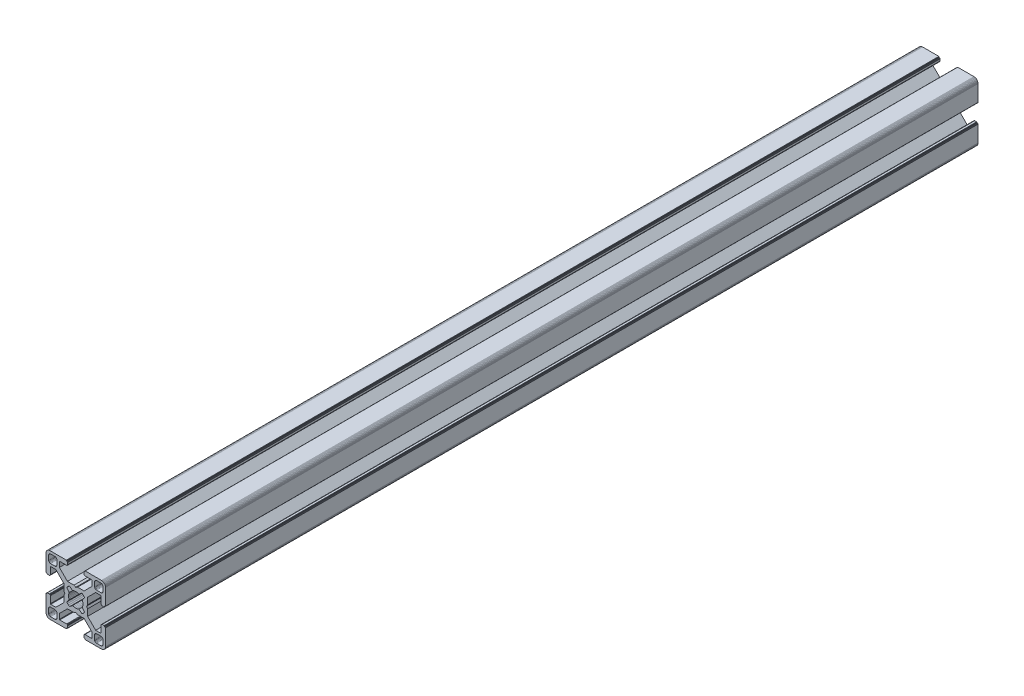
from build123d import *

# Parameters (mm, degrees)
BOSS_EXTRUDE1_DEPTH = 440


with BuildPart() as part:
    # Sketch1 → Boss-Extrude1 (new body)
    with BuildSketch(Plane.XY):
        Polygon((28.34729664, 29.969613999), (28.000000864, 29.999999329), (19.750000909, 29.999999329), (19.715268165, 29.996961355), (19.681595266, 29.987938702), (19.649999216, 29.973205179), (19.621443003, 29.953207821), (19.596790895, 29.928557575), (19.576793537, 29.899999499), (19.562061876, 29.868405312), (19.55303736, 29.834728688), (19.549999386, 29.799999669), (19.549999386, 29.699999839), (19.546961412, 29.665268958), (19.537936896, 29.631596059), (19.523203373, 29.599998146), (19.503207877, 29.571441934), (19.478557631, 29.546789825), (19.449999556, 29.526794329), (19.418403506, 29.512060806), (19.384728745, 29.503038153), (19.349999726, 29.500000179), (19.249999896, 29.500000179), (19.215267517, 29.496958527), (19.181592755, 29.487935874), (19.149996706, 29.47320235), (19.12143863, 29.453206855), (19.096788384, 29.428554746), (19.076791026, 29.399996671), (19.062057503, 29.368402484), (19.05303485, 29.334725859), (19.049996876, 29.299998703), (19.049996876, 28.39999837), (19.059110798, 28.29580945), (19.08618062, 28.194785165), (19.13038119, 28.099997016), (19.190369539, 28.014324653), (19.264324002, 27.94037019), (19.349996366, 27.88038184), (19.444784515, 27.836181271), (19.545806937, 27.809111449), (19.650010894, 27.799984574), (23.050010706, 27.799984574), (23.084741588, 27.7969466), (23.118414487, 27.787923946), (23.150012399, 27.773190423), (23.178568612, 27.753193065), (23.203220721, 27.728542819), (23.223218079, 27.699984744), (23.237949739, 27.668386831), (23.246974255, 27.634713932), (23.25001142, 27.59998608), (23.25001142, 25.049987618), (19.204474482, 20.999982084), (15.900007876, 20.999982084), (15.000008474, 20.48483404), (14.10000814, 20.999982084), (10.795543398, 20.999982084), (7.997342887, 23.801274731), (6.750011387, 25.049984589), (6.750011387, 27.599983051), (6.753049362, 27.634713932), (6.762072946, 27.668386831), (6.776805538, 27.699984744), (6.796801965, 27.728542819), (6.821454073, 27.753193065), (6.850011218, 27.773190423), (6.881607267, 27.787923946), (6.915282029, 27.7969466), (6.950011048, 27.799984574), (10.350011791, 27.799984574), (10.45420071, 27.809098497), (10.555223133, 27.836168318), (10.650011282, 27.880368888), (10.735683645, 27.940357238), (10.809638108, 28.014311701), (10.869626458, 28.099984064), (10.913827027, 28.194772213), (10.940895918, 28.295796498), (10.950010772, 28.399985417), (10.950010772, 29.299985751), (10.946974575, 29.334739239), (10.93795065, 29.368415522), (10.923215933, 29.400009153), (10.903218427, 29.428566473), (10.878566319, 29.45321765), (10.849999264, 29.473204166), (10.818403214, 29.487937689), (10.784728453, 29.496960342), (10.749999434, 29.500000179), (10.649999604, 29.500000179), (10.615270585, 29.503038153), (10.581595823, 29.512060806), (10.549999774, 29.526794329), (10.521441698, 29.546789825), (10.496791452, 29.571441934), (10.476795025, 29.599998146), (10.462061502, 29.631596059), (10.453037918, 29.665268958), (10.449999943, 29.699999839), (10.449999943, 29.799999669), (10.446961969, 29.834728688), (10.437938385, 29.868405312), (10.423205793, 29.899999499), (10.403208435, 29.928557575), (10.378557257, 29.953207821), (10.350000113, 29.973205179), (10.318404064, 29.987938702), (10.284729302, 29.996961355), (10.250000283, 29.999999329), (1.999999397, 29.999999329), (1.652702689, 29.969613999), (1.315958682, 29.879383743), (0.999999233, 29.732050374), (0.714424066, 29.532089829), (0.467910431, 29.285576195), (0.267948955, 28.999999166), (0.120614655, 28.684040532), (0.030384399, 28.34729664), (0, 28.000000864), (0, 19.750000909), (0.003037974, 19.715268165), (0.012061559, 19.681595266), (0.026795082, 19.649999216), (0.046790577, 19.621441141), (0.071442686, 19.596789032), (0.09999983, 19.576793537), (0.13159588, 19.562060013), (0.165270641, 19.55303736), (0.19999966, 19.549999386), (0.299999461, 19.549999386), (0.334728509, 19.546959549), (0.368403242, 19.537936896), (0.399999321, 19.523203373), (0.428556465, 19.503207877), (0.453208573, 19.478555769), (0.473204069, 19.449997693), (0.487937592, 19.418403506), (0.496961176, 19.384728745), (0.499999151, 19.349999726), (0.499999151, 19.249998033), (0.503038056, 19.215269014), (0.512060709, 19.181594253), (0.526794232, 19.150000066), (0.546790194, 19.121441524), (0.571441837, 19.096789882), (0.60000029, 19.076794925), (0.631595686, 19.062061999), (0.665270619, 19.053039982), (0.700000626, 19.050000801), (1.60000096, 19.050000801), (1.704189879, 19.059116587), (1.805213233, 19.086186409), (1.90000045, 19.130385115), (1.985673745, 19.190375328), (2.059627277, 19.264327928), (2.119616325, 19.350002154), (2.163816196, 19.444788441), (2.190886018, 19.545812726), (2.200000872, 19.650001645), (2.200000872, 23.050001457), (2.203039777, 23.084732338), (2.212062431, 23.118405237), (2.226795954, 23.15000315), (2.246792381, 23.178559362), (2.271443558, 23.203211471), (2.300000702, 23.223206967), (2.331596752, 23.23794049), (2.365271513, 23.246965006), (2.400001464, 23.250001117), (4.950000857, 23.250001117), (7.997332093, 20.202670812), (8.995535423, 19.204467788), (8.995535423, 15.900001182), (9.515148227, 15.00000178), (8.995535423, 14.100002378), (8.995535423, 10.795536704), (4.950000857, 6.750002138), (2.400001464, 6.750002138), (2.365271513, 6.753040112), (2.331596752, 6.762063697), (2.300000702, 6.77679722), (2.271443558, 6.796793647), (2.246792381, 6.821444824), (2.226795954, 6.850001968), (2.212062431, 6.881598018), (2.203039777, 6.915272779), (2.200000872, 6.950002729), (2.200000872, 10.350002542), (2.190896812, 10.454174265), (2.16382699, 10.555197618), (2.119627119, 10.649984836), (2.059638071, 10.735658131), (1.985684539, 10.809611663), (1.900011244, 10.869600944), (1.805224027, 10.913800582), (1.704200673, 10.940870404), (1.600011754, 10.949986189), (0.70001142, 10.949986189), (0.665281355, 10.946948596), (0.631606253, 10.937926283), (0.600010578, 10.923193954), (0.571451747, 10.903199537), (0.546799638, 10.87854836), (0.526794232, 10.850000195), (0.512060709, 10.818404146), (0.503038056, 10.784730315), (0.499999151, 10.750000365), (0.499999151, 10.650000535), (0.496961176, 10.615270585), (0.487937592, 10.581596754), (0.473204069, 10.550000705), (0.453208573, 10.521443561), (0.428556465, 10.496791452), (0.399999321, 10.476795956), (0.368403242, 10.462062433), (0.334728509, 10.453038849), (0.299999461, 10.449999943), (0.19999966, 10.449999943), (0.165270641, 10.446961969), (0.13159588, 10.437939316), (0.09999983, 10.423205793), (0.071442686, 10.403209366), (0.046790577, 10.378558189), (0.026795082, 10.350000113), (0.012061559, 10.318404064), (0.003037974, 10.284729302), (0, 10.250000283), (0, 1.999999397), (0.030384399, 1.652702689), (0.120614655, 1.315958682), (0.267948955, 0.999999233), (0.467910431, 0.714424066), (0.714424066, 0.467910431), (0.999999233, 0.267948955), (1.315958682, 0.120614655), (1.652702689, 0.030384399), (1.999999397, 0), (10.250000283, 0), (10.284729302, 0.003037974), (10.318404064, 0.012061559), (10.350000113, 0.026795082), (10.378557257, 0.046790577), (10.403208435, 0.071442686), (10.423205793, 0.09999983), (10.437938385, 0.13159588), (10.446961969, 0.165270641), (10.449999943, 0.19999966), (10.449999943, 0.300000422), (10.453037918, 0.334729441), (10.462061502, 0.368404202), (10.476795025, 0.400000252), (10.496791452, 0.428557396), (10.521441698, 0.453208573), (10.549999774, 0.473205), (10.581595823, 0.487938523), (10.615270585, 0.496961176), (10.649999604, 0.500000082), (10.749999434, 0.500000082), (10.784728453, 0.503038056), (10.818403214, 0.512060709), (10.849999264, 0.526794232), (10.878547894, 0.546800104), (10.903198606, 0.571451747), (10.923194493, 0.6000102), (10.93792742, 0.631606528), (10.946949437, 0.66528146), (10.950010772, 0.699984975), (10.950010772, 1.599985308), (10.940895918, 1.704174228), (10.913827027, 1.805197581), (10.869626458, 1.89998573), (10.809638108, 1.985658094), (10.735683645, 2.059612557), (10.650011282, 2.119600674), (10.555223133, 2.163801476), (10.45420071, 2.190870367), (10.350011791, 2.199985221), (6.950011048, 2.199985221), (6.915282029, 2.203024126), (6.881607267, 2.212046779), (6.850011218, 2.226780302), (6.821454073, 2.246776729), (6.796801965, 2.271427907), (6.776805538, 2.299985982), (6.762072946, 2.331582032), (6.753049362, 2.365256793), (6.750011387, 2.399985812), (6.750011387, 4.949985206), (9.787457566, 7.990785077), (10.795545277, 8.999985833), (14.100010019, 8.999985833), (15.000010353, 9.515133877), (15.900009756, 8.999985833), (19.204476361, 8.999985833), (20.21256413, 7.990786065), (23.25001142, 4.949988235), (23.25001142, 2.399988841), (23.246974255, 2.365256793), (23.237949739, 2.331582032), (23.223218079, 2.299985982), (23.203220721, 2.271427907), (23.178568612, 2.246776729), (23.150012399, 2.226780302), (23.118414487, 2.212046779), (23.084741588, 2.203024126), (23.050010706, 2.199985221), (19.650010894, 2.199985221), (19.545806937, 2.190883319), (19.444784515, 2.163814428), (19.349996366, 2.119613626), (19.264324002, 2.059625509), (19.190369539, 1.985671046), (19.13038119, 1.899998682), (19.08618062, 1.805210533), (19.059110798, 1.70418718), (19.049996876, 1.599998261), (19.049996876, 0.699997927), (19.053035506, 0.665268966), (19.062058795, 0.631594374), (19.076792915, 0.599998603), (19.096790813, 0.571440905), (19.121441524, 0.546790194), (19.149999978, 0.526794306), (19.181596306, 0.51206138), (19.215271238, 0.503039363), (19.249999896, 0.500000082), (19.349999726, 0.500000082), (19.384728745, 0.496961176), (19.418403506, 0.487938523), (19.449999556, 0.473205), (19.478557631, 0.453208573), (19.503207877, 0.428557396), (19.523203373, 0.400000252), (19.537936896, 0.368404202), (19.546961412, 0.334729441), (19.549999386, 0.300000422), (19.549999386, 0.19999966), (19.55303736, 0.165270641), (19.562061876, 0.13159588), (19.576793537, 0.09999983), (19.596789964, 0.071441755), (19.621442072, 0.046789646), (19.649998285, 0.02679415), (19.681594335, 0.012060627), (19.715267234, 0.003037043), (19.750000909, 0), (28.000000864, 0), (28.34729664, 0.030384399), (28.684040532, 0.120614655), (28.999999166, 0.267948955), (29.285576195, 0.467910431), (29.532089829, 0.714424066), (29.732050374, 0.999999233), (29.879383743, 1.315958682), (29.969613999, 1.652702689), (29.999999329, 1.999999397), (29.999999329, 10.250000283), (29.996974806, 10.284715361), (29.987951516, 10.318389952), (29.973217396, 10.349985723), (29.953219499, 10.378543421), (29.928568787, 10.403194133), (29.899999499, 10.423205793), (29.868405312, 10.437939316), (29.834728688, 10.446961969), (29.799999669, 10.449999943), (29.699999839, 10.449999943), (29.664909937, 10.453400043), (29.631233313, 10.462423628), (29.599637263, 10.477157151), (29.57108105, 10.497152646), (29.546427079, 10.521804755), (29.526433446, 10.550361899), (29.511699923, 10.581957949), (29.502675407, 10.615631779), (29.499637433, 10.650361729), (29.499637433, 10.750361559), (29.49697202, 10.784715548), (29.487949367, 10.818389378), (29.473215844, 10.849985428), (29.453220348, 10.878542572), (29.428568239, 10.90319468), (29.400010164, 10.923190176), (29.368415977, 10.937923699), (29.334741215, 10.946947284), (29.300012197, 10.949986189), (28.400011863, 10.949986189), (28.29581215, 10.9408876), (28.194787865, 10.913817778), (28.099999716, 10.86961814), (28.014327352, 10.809628859), (27.940374752, 10.735675327), (27.880384539, 10.650002032), (27.836185833, 10.555214814), (27.809114148, 10.454191461), (27.800000225, 10.350002542), (27.800000225, 6.950002729), (27.796962251, 6.915272779), (27.787939598, 6.881598018), (27.773206075, 6.850001968), (27.753208716, 6.821444824), (27.728558471, 6.796793647), (27.700000395, 6.77679722), (27.668404345, 6.762063697), (27.634729584, 6.753040112), (27.599998702, 6.750002138), (25.05000024, 6.750002138), (23.809199132, 7.99080223), (21.004464477, 10.795534588), (21.004464477, 14.100000262), (20.484851673, 14.999999665), (21.004464477, 15.899999067), (21.004464477, 19.204465672), (25.05000024, 23.250001117), (27.599998702, 23.250001117), (27.634729584, 23.246965006), (27.668404345, 23.23794049), (27.700000395, 23.223206967), (27.728558471, 23.203211471), (27.753208716, 23.178559362), (27.773206075, 23.15000315), (27.787939598, 23.118405237), (27.796962251, 23.084732338), (27.800000225, 23.050001457), (27.800000225, 19.650001645), (27.809114148, 19.545812726), (27.836185833, 19.444788441), (27.880384539, 19.350002154), (27.940370508, 19.264323684), (28.014323108, 19.190371084), (28.099995472, 19.130380872), (28.194783621, 19.086182165), (28.295807906, 19.059112343), (28.400001069, 19.050000801), (29.300001402, 19.050000801), (29.334730421, 19.053040638), (29.368405183, 19.062063291), (29.39999937, 19.076796814), (29.42819671, 19.097149726), (29.452848353, 19.1218023), (29.472843309, 19.150360754), (29.487576235, 19.181955219), (29.496598252, 19.215630151), (29.499637433, 19.250359227), (29.499637433, 19.35036092), (29.502675407, 19.385089939), (29.511699923, 19.4187647), (29.526433446, 19.450358887), (29.546427079, 19.478916963), (29.57108105, 19.503569071), (29.599637263, 19.523564567), (29.631233313, 19.53829809), (29.664909937, 19.547320743), (29.699999839, 19.549999386), (29.799999669, 19.549999386), (29.834728688, 19.55303736), (29.868405312, 19.562060013), (29.899999499, 19.576793537), (29.928557575, 19.596789032), (29.953207821, 19.621441141), (29.973205179, 19.649999216), (29.987938702, 19.681595266), (29.996961355, 19.715268165), (29.999999329, 19.750000909), (29.999999329, 28.000000864), (29.969613999, 28.34729664), (29.879383743, 28.684040532), (29.732050374, 28.999999166), (29.532089829, 29.285576195), (29.285576195, 29.532089829), (28.999999166, 29.732050374), (28.684040532, 29.879383743), align=None)
        Polygon((1.299998723, 25.499999523), (1.299998723, 27.699999511), (1.312309876, 27.856435627), (1.348942518, 28.009016067), (1.408992335, 28.153989464), (1.490981318, 28.287785128), (1.592892222, 28.407108039), (1.71221327, 28.50901708), (1.846008119, 28.591006994), (1.9909814, 28.651056811), (2.143563703, 28.687689453), (2.299998887, 28.699999675), (4.499998875, 28.699999675), (4.656434059, 28.687689453), (4.809016362, 28.651056811), (4.953989759, 28.591006994), (5.087784491, 28.50901708), (5.207106471, 28.407108039), (5.309016444, 28.287785128), (5.391005427, 28.153989464), (5.451056175, 28.009016067), (5.487687886, 27.856435627), (5.499999039, 27.699999511), (5.499999039, 25.499999523), (5.487687886, 25.34356527), (5.451056175, 25.190982968), (5.391005427, 25.04600957), (5.309016444, 24.912213907), (5.207106471, 24.792892858), (5.087784491, 24.690981954), (4.953989759, 24.60899204), (4.809016362, 24.548944086), (4.656434059, 24.512309581), (4.499998875, 24.499999359), (2.299998887, 24.499999359), (2.143563703, 24.512309581), (1.9909814, 24.548944086), (1.846008119, 24.60899204), (1.71221327, 24.690981954), (1.592892222, 24.792892858), (1.490981318, 24.912213907), (1.408992335, 25.04600957), (1.348942518, 25.190982968), (1.312309876, 25.34356527), align=None, mode=Mode.SUBTRACT)
        Polygon((25.34356527, 28.687689453), (25.499999523, 28.699999675), (27.699999511, 28.699999675), (27.856435627, 28.687689453), (28.009017929, 28.651056811), (28.153991327, 28.591006994), (28.28778699, 28.50901708), (28.407108039, 28.407108039), (28.50901708, 28.287785128), (28.591006994, 28.153989464), (28.651056811, 28.009016067), (28.687689453, 27.856435627), (28.700001538, 27.699999511), (28.700001538, 25.499999523), (28.687689453, 25.34356527), (28.651056811, 25.190982968), (28.591006994, 25.04600957), (28.50901708, 24.912213907), (28.407108039, 24.792892858), (28.28778699, 24.690981954), (28.153991327, 24.60899204), (28.009017929, 24.548944086), (27.856435627, 24.512309581), (27.699999511, 24.499999359), (25.499999523, 24.499999359), (25.34356527, 24.512309581), (25.190982968, 24.548944086), (25.04600957, 24.60899204), (24.912215769, 24.690981954), (24.792892858, 24.792892858), (24.690981954, 24.912213907), (24.608993903, 25.04600957), (24.548944086, 25.190982968), (24.512311444, 25.34356527), (24.500001222, 25.499999523), (24.500001222, 27.699999511), (24.512311444, 27.856435627), (24.548944086, 28.009016067), (24.608993903, 28.153989464), (24.690981954, 28.287785128), (24.792892858, 28.407108039), (24.912215769, 28.50901708), (25.04600957, 28.591006994), (25.190982968, 28.651056811), align=None, mode=Mode.SUBTRACT)
        Polygon((14.999999665, 18.649999052), (15.550030395, 18.608318642), (16.087498516, 18.484227359), (16.600128263, 18.280562013), (18.13592948, 19.518401474), (18.644984812, 19.11874488), (19.103571773, 18.662061542), (19.505336881, 18.154669553), (18.280562013, 16.600130126), (18.484227359, 16.087498516), (18.608318642, 15.550030395), (18.649999052, 14.999999665), (18.608318642, 14.449968934), (18.484227359, 13.912500814), (18.280562013, 13.399870135), (19.505336881, 11.845329776), (19.103571773, 11.337937787), (18.644984812, 10.881252587), (18.13592948, 10.481598787), (16.600128263, 11.719437316), (16.087498516, 11.515771039), (15.550030395, 11.391680688), (14.999999665, 11.349999346), (14.449968934, 11.391680688), (13.912500814, 11.515771039), (13.399870135, 11.719437316), (11.864069849, 10.481598787), (11.355013587, 10.881252587), (10.896427557, 11.337937787), (10.494662449, 11.845329776), (11.719438247, 13.399870135), (11.515771039, 13.912500814), (11.391680688, 14.449968934), (11.349999346, 14.999999665), (11.391680688, 15.550030395), (11.515771039, 16.087498516), (11.719438247, 16.600130126), (10.494662449, 18.154669553), (10.896427557, 18.662061542), (11.355013587, 19.11874488), (11.864069849, 19.518401474), (13.399870135, 18.280562013), (13.912500814, 18.484227359), (14.449968934, 18.608318642), align=None, mode=Mode.SUBTRACT)
        Polygon((4.499998875, 1.299999771), (2.299998887, 1.299999771), (2.143563703, 1.312310807), (1.9909814, 1.348942518), (1.846008119, 1.408992335), (1.71221327, 1.490982249), (1.592892222, 1.592892222), (1.490981318, 1.712214202), (1.408992335, 1.846008934), (1.348942518, 1.990982331), (1.312309876, 2.143564634), (1.299998723, 2.299998887), (1.299998723, 4.499999806), (1.312309876, 4.656434059), (1.348942518, 4.809017293), (1.408992335, 4.95399069), (1.490981318, 5.087785423), (1.592892222, 5.207106471), (1.71221327, 5.309017375), (1.846008119, 5.391006358), (1.9909814, 5.451056175), (2.143563703, 5.487688817), (2.299998887, 5.49999997), (4.499998875, 5.49999997), (4.656434059, 5.487688817), (4.809016362, 5.451056175), (4.953989759, 5.391006358), (5.087784491, 5.309017375), (5.207106471, 5.207106471), (5.309016444, 5.087785423), (5.391005427, 4.95399069), (5.451056175, 4.809017293), (5.487687886, 4.656434059), (5.499999039, 4.499999806), (5.499999039, 2.299998887), (5.487687886, 2.143564634), (5.451056175, 1.990982331), (5.391005427, 1.846008934), (5.309016444, 1.712214202), (5.207106471, 1.592892222), (5.087784491, 1.490982249), (4.953989759, 1.408992335), (4.809016362, 1.348942518), (4.656434059, 1.312310807), align=None, mode=Mode.SUBTRACT)
        Polygon((27.699999511, 1.299999771), (25.499999523, 1.299999771), (25.34356527, 1.312310807), (25.190982968, 1.348942518), (25.04600957, 1.408992335), (24.912215769, 1.490982249), (24.792892858, 1.592892222), (24.690981954, 1.712214202), (24.608993903, 1.846008934), (24.548944086, 1.990982331), (24.512311444, 2.143564634), (24.500001222, 2.299998887), (24.500001222, 4.499999806), (24.512311444, 4.656434059), (24.548944086, 4.809017293), (24.608993903, 4.95399069), (24.690981954, 5.087785423), (24.792892858, 5.207106471), (24.912215769, 5.309017375), (25.04600957, 5.391006358), (25.190982968, 5.451056175), (25.34356527, 5.487688817), (25.499999523, 5.49999997), (27.699999511, 5.49999997), (27.856435627, 5.487688817), (28.009017929, 5.451056175), (28.153991327, 5.391006358), (28.28778699, 5.309017375), (28.407108039, 5.207106471), (28.50901708, 5.087785423), (28.591006994, 4.95399069), (28.651056811, 4.809017293), (28.687689453, 4.656434059), (28.700001538, 4.499999806), (28.700001538, 2.299998887), (28.687689453, 2.143564634), (28.651056811, 1.990982331), (28.591006994, 1.846008934), (28.50901708, 1.712214202), (28.407108039, 1.592892222), (28.28778699, 1.490982249), (28.153991327, 1.408992335), (28.009017929, 1.348942518), (27.856435627, 1.312310807), align=None, mode=Mode.SUBTRACT)
    extrude(amount=-BOSS_EXTRUDE1_DEPTH)


solid = part.part
